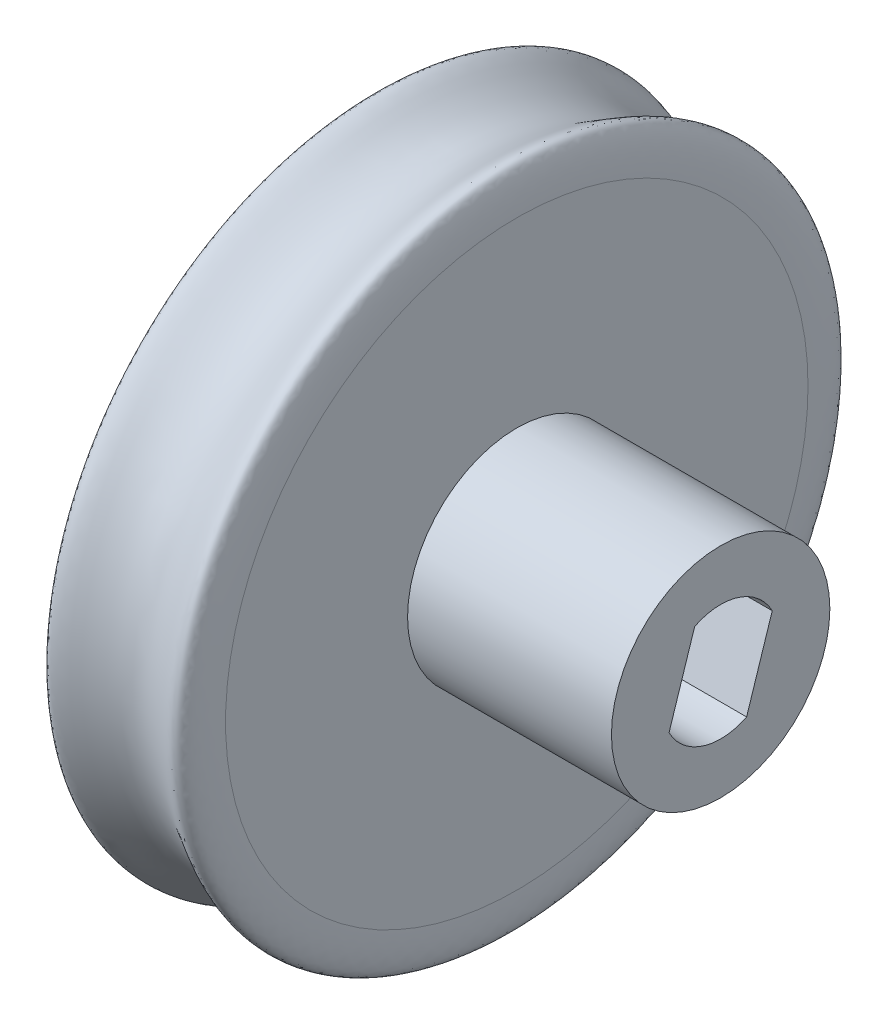
from build123d import *

# Parameters (mm, degrees)
SKETCH2_R           = 4.7625
BOSS_EXTRUDE1_DEPTH = 8.89
CUT_EXTRUDE1_START  = -3.175
CUT_EXTRUDE1_DEPTH  = 3.175


with BuildPart() as part:
    # Sketch1 → Revolve1 (revolve)
    with BuildSketch(Plane.XY):
        with BuildLine():
            Line((0, 0), (-3.175, 0))
            Line((-3.175, 0), (-3.175, 12.7))
            add(Edge.make_bspline(
                [(-3.175, 12.7), (-3.175, 19.05), (0, 6.35), (3.175, 19.05), (3.175, 12.7)],
                knots=[0, 0, 0, 0, 0, 1, 1, 1, 1, 1], degree=4))
            Line((3.175, 12.7), (3.175, 0))
            Line((3.175, 0), (0, 0))
        make_face()
    revolve(axis=Axis((0, 0, 0), (-1, 0, 0)))

    # Sketch2 → Boss-Extrude1 (add)
    with BuildSketch(Plane(origin=(3.175, 0, 0), x_dir=(0, 0, -1), z_dir=(1, 0, 0))):
        Circle(SKETCH2_R)
        with BuildLine():
            Line((1.132738197, -2.273434446), (2.250324949, 1.177980315))
            ThreePointArc((2.250324949, 1.177980315), (0.782467236, 2.416473676), (-1.132738197, 2.273434446))
            Line((-1.132738197, 2.273434446), (-2.250324949, -1.177980315))
            ThreePointArc((-2.250324949, -1.177980315), (-0.782467236, -2.416473676), (1.132738197, -2.273434446))
        make_face(mode=Mode.SUBTRACT)
    extrude(amount=BOSS_EXTRUDE1_DEPTH)

    # Sketch2_2 → Cut-Extrude1 (cut)
    with BuildSketch(Plane(origin=(3.175, 0, 0), x_dir=(0, 0, -1), z_dir=(1, 0, 0)).offset(CUT_EXTRUDE1_START)):
        with BuildLine():
            Line((1.132738197, -2.273434446), (2.250324949, 1.177980315))
            ThreePointArc((2.250324949, 1.177980315), (0.782467236, 2.416473676), (-1.132738197, 2.273434446))
            Line((-1.132738197, 2.273434446), (-2.250324949, -1.177980315))
            ThreePointArc((-2.250324949, -1.177980315), (-0.782467236, -2.416473676), (1.132738197, -2.273434446))
        make_face()
    extrude(amount=CUT_EXTRUDE1_DEPTH, mode=Mode.SUBTRACT)


solid = part.part
